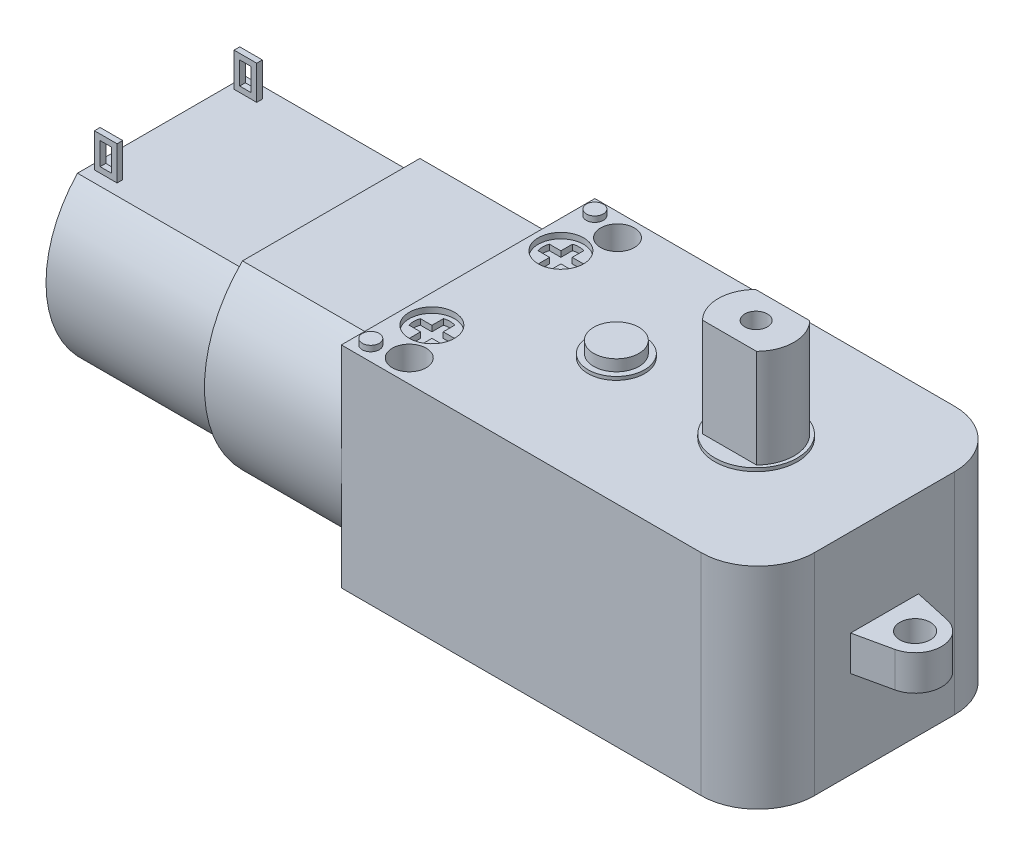
from build123d import *

# Parameters (mm, degrees)
SKETCH1_W       = 36.8
SKETCH1_H       = 22.4
EXTRUDE1_DEPTH  = 9.3
FILLET1_R       = 5
SKETCH2_R       = 1.35
EXTRUDE2_DEPTH  = 1.55
SKETCH3_R       = 3.65
SKETCH3_R_2     = 2.5
EXTRUDE3_DEPTH  = 0.3
SKETCH4_R       = 1
EXTRUDE4_DEPTH  = 8.7
SKETCH6_R       = 2
EXTRUDE5_DEPTH  = 1
SKETCH7_R       = 1.5
EXTRUDE6_DEPTH  = 19.6
SKETCH8_R       = 2
EXTRUDE7_DEPTH  = 0.5
EXTRUDE8_DEPTH  = 0.5
SKETCH10_R      = 0.75
EXTRUDE9_DEPTH  = 0.5
EXTRUDE11_DEPTH = 12.1
EXTRUDE12_DEPTH = 15
SKETCH14_R      = 4
EXTRUDE13_DEPTH = 1
SKETCH15_R      = 1
EXTRUDE14_DEPTH = 1
SKETCH16_W      = 2
SKETCH16_H      = 0.5
EXTRUDE15_DEPTH = 3
SKETCH17_W      = 1
SKETCH17_H      = 2
EXTRUDE16_DEPTH = 18.618894796


with BuildPart() as part:
    # Sketch1 → Extrude1 (new body, symmetric)
    with BuildSketch(Plane(origin=(0, 0, 0), x_dir=(1, 0, 0), z_dir=(0, 1, 0))):
        with Locations((18.4, 11.2)):
            Rectangle(SKETCH1_W, SKETCH1_H)
    extrude(amount=EXTRUDE1_DEPTH, both=True)

    # Fillet1
    fillet1_edges = [part.edges().sort_by_distance(p)[0] for p in [
        (36.8, 0, -22.4),
        (36.8, 0, 0),
    ]]
    fillet(fillet1_edges, radius=FILLET1_R)

    # Sketch2 → Extrude2 (add, symmetric)
    with BuildSketch(Plane(origin=(0, 0, 0), x_dir=(1, 0, 0), z_dir=(0, 1, 0))):
        with BuildLine():
            Line((36.8, 14.2), (40.004789912, 13.495144254))
            ThreePointArc((40.004789912, 13.495144254), (41.85, 11.2), (40.004789912, 8.904855746))
            Line((40.004789912, 8.904855746), (36.8, 8.2))
            Line((36.8, 8.2), (36.8, 14.2))
        make_face()
        with Locations(Location((39.5, 11.2, 0), (0, 0, 270))):  # turned: the seam where the file's is
            Circle(SKETCH2_R, mode=Mode.SUBTRACT)
    extrude(amount=EXTRUDE2_DEPTH, both=True)

    # Sketch3 → Extrude3 (add)
    with BuildSketch(Plane(origin=(0, 9.3, 0), x_dir=(1, 0, 0), z_dir=(0, 1, 0))):
        with Locations(Location((25.45, 11.2, 0), (0, 0, 90))):  # turned: the seam where the file's is
            Circle(SKETCH3_R)
        with Locations(Location((13.1, 11.2, 0), (0, 0, 90))):  # turned: the seam where the file's is
            Circle(SKETCH3_R_2)
    extrude(amount=EXTRUDE3_DEPTH)

    # Sketch4 → Extrude4 (add)
    with BuildSketch(Plane(origin=(0, 9.6, 0), x_dir=(1, 0, 0), z_dir=(0, 1, 0))):
        with BuildLine():
            Line((23.062532723, 8.85), (27.837467277, 8.85))
            ThreePointArc((27.837467277, 8.85), (28.8, 11.2), (27.837467277, 13.55))
            Line((27.837467277, 13.55), (23.062532723, 13.55))
            ThreePointArc((23.062532723, 13.55), (22.1, 11.2), (23.062532723, 8.85))
        make_face()
        with Locations(Location((25.45, 11.2, 0), (0, 0, 270))):  # turned: the seam where the file's is
            Circle(SKETCH4_R, mode=Mode.SUBTRACT)
    extrude(amount=EXTRUDE4_DEPTH)

    # Sketch6 → Extrude5 (add)
    with BuildSketch(Plane(origin=(0, 9.6, 0), x_dir=(1, 0, 0), z_dir=(0, 1, 0))):
        with Locations(Location((13.1, 11.2, 0), (0, 0, 270))):  # turned: the seam where the file's is
            Circle(SKETCH6_R)
    extrude(amount=EXTRUDE5_DEPTH)

    # Sketch7 → Extrude6 (cut, through all)
    with BuildSketch(Plane(origin=(0, 9.3, 0), x_dir=(1, 0, 0), z_dir=(0, 1, 0))):
        with Locations(Location((4, 20.4, 0), (0, 0, 270))):  # turned: the seam where the file's is
            Circle(SKETCH7_R)
        with Locations(Location((4, 2, 0), (0, 0, 270))):  # turned: the seam where the file's is
            Circle(SKETCH7_R)
    extrude(amount=-EXTRUDE6_DEPTH, mode=Mode.SUBTRACT)

    # Sketch8 → Extrude7 (cut)
    with BuildSketch(Plane(origin=(0, 9.3, 0), x_dir=(1, 0, 0), z_dir=(0, 1, 0))):
        with Locations(Location((2.5, 16.9, 0), (0, 0, 270))):  # turned: the seam where the file's is
            Circle(SKETCH8_R)
        with Locations(Location((2.5, 5.5, 0), (0, 0, 270))):  # turned: the seam where the file's is
            Circle(SKETCH8_R)
    extrude(amount=-EXTRUDE7_DEPTH, mode=Mode.SUBTRACT)

    # Sketch9 → Extrude8 (cut)
    with BuildSketch(Plane(origin=(0, 8.8, 0), x_dir=(1, 0, 0), z_dir=(0, 1, 0))):
        with BuildLine():
            Line((2, 7.019868415), (2, 6))
            Line((2, 6), (0.980131585, 6))
            ThreePointArc((0.980131585, 6), (0.9, 5.5), (0.980131585, 5))
            Line((0.980131585, 5), (2, 5))
            Line((2, 5), (2, 3.980131585))
            ThreePointArc((2, 3.980131585), (2.5, 3.9), (3, 3.980131585))
            Line((3, 3.980131585), (3, 5))
            Line((3, 5), (4.019868415, 5))
            ThreePointArc((4.019868415, 5), (4.1, 5.5), (4.019868415, 6))
            Line((4.019868415, 6), (3, 6))
            Line((3, 6), (3, 7.019868415))
            ThreePointArc((3, 7.019868415), (2.5, 7.1), (2, 7.019868415))
        make_face()
        with BuildLine():
            Line((4.019868415, 17.4), (3, 17.4))
            Line((3, 17.4), (3, 18.419868415))
            ThreePointArc((3, 18.419868415), (2.5, 18.5), (2, 18.419868415))
            Line((2, 18.419868415), (2, 17.4))
            Line((2, 17.4), (0.980131585, 17.4))
            ThreePointArc((0.980131585, 17.4), (0.9, 16.9), (0.980131585, 16.4))
            Line((0.980131585, 16.4), (2, 16.4))
            Line((2, 16.4), (2, 15.380131585))
            ThreePointArc((2, 15.380131585), (2.5, 15.3), (3, 15.380131585))
            Line((3, 15.380131585), (3, 16.4))
            Line((3, 16.4), (4.019868415, 16.4))
            ThreePointArc((4.019868415, 16.4), (4.1, 16.9), (4.019868415, 17.4))
        make_face()
    extrude(amount=-EXTRUDE8_DEPTH, mode=Mode.SUBTRACT)

    # Sketch10 → Extrude9 (add)
    with BuildSketch(Plane(origin=(0, 9.3, 0), x_dir=(1, 0, 0), z_dir=(0, 1, 0))):
        with Locations(Location((1.3, 21.1, 0), (0, 0, 90))):  # turned: the seam where the file's is
            Circle(SKETCH10_R)
        with Locations(Location((1.3, 1.3, 0), (0, 0, 90))):  # turned: the seam where the file's is
            Circle(SKETCH10_R)
    extrude(amount=EXTRUDE9_DEPTH)

    # Sketch12 → Extrude11 (add)
    with BuildSketch(Plane.ZY):
        with BuildLine():
            Line((-19.038367177, 8), (-3.361632823, 8))
            ThreePointArc((-3.361632823, 8), (0, 0), (-3.361632823, -8))
            Line((-3.361632823, -8), (-19.038367177, -8))
            ThreePointArc((-19.038367177, -8), (-22.4, 0), (-19.038367177, 8))
        make_face()
    extrude(amount=EXTRUDE11_DEPTH)

    # Sketch13 → Extrude12 (add)
    with BuildSketch(Plane.ZY.offset(12.1)):
        with BuildLine():
            Line((-18.618894796, -7), (-3.781105204, -7))
            ThreePointArc((-3.781105204, -7), (-1, 0), (-3.781105204, 7))
            Line((-3.781105204, 7), (-18.618894796, 7))
            ThreePointArc((-18.618894796, 7), (-21.4, 0), (-18.618894796, -7))
        make_face()
    extrude(amount=EXTRUDE12_DEPTH)

    # Sketch14 → Extrude13 (add)
    with BuildSketch(Plane.ZY.offset(27.1)):
        with Locations((-11.2, 0)):
            Circle(SKETCH14_R)
    extrude(amount=EXTRUDE13_DEPTH)

    # Sketch15 → Extrude14 (add)
    with BuildSketch(Plane.ZY.offset(28.1)):
        with Locations((-11.2, 0)):
            Circle(SKETCH15_R)
    extrude(amount=EXTRUDE14_DEPTH)

    # Sketch16 → Extrude15 (add)
    with BuildSketch(Plane(origin=(0, 7, 0), x_dir=(1, 0, 0), z_dir=(0, 1, 0))):
        with Locations((-25.6, 17.368894796)):
            Rectangle(SKETCH16_W, SKETCH16_H)
        with Locations((-25.6, 5.031105204)):
            Rectangle(SKETCH16_W, SKETCH16_H)
    extrude(amount=EXTRUDE15_DEPTH)

    # Sketch17 → Extrude16 (cut, through all)
    with BuildSketch(Plane.XY.offset(-4.781105204)):
        with Locations((-25.6, 8.5)):
            Rectangle(SKETCH17_W, SKETCH17_H)
    extrude(amount=-EXTRUDE16_DEPTH, mode=Mode.SUBTRACT)


solid = part.part
